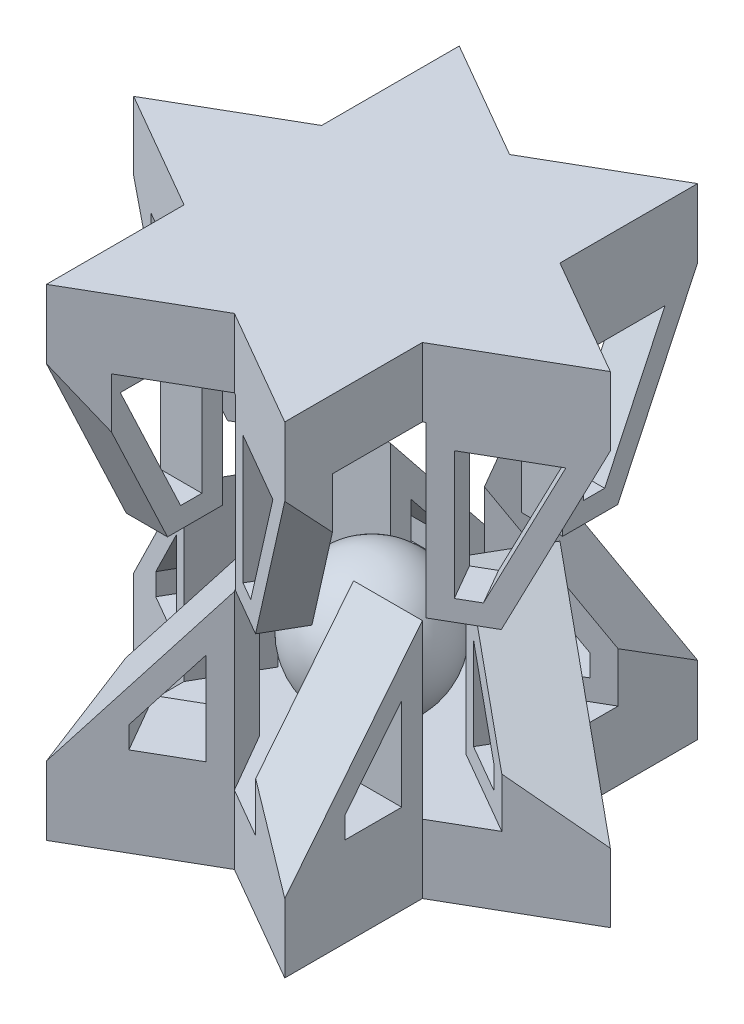
from build123d import *

# Parameters (mm, degrees)
BOSS_EXTRUDE1_DEPTH = 5
BOSS_EXTRUDE2_START = 30
BOSS_EXTRUDE2_DEPTH = 5
BOSS_EXTRUDE3_DEPTH = 5
CIRPATTERN3_COUNT   = 6
SKETCH6_W           = 10
SKETCH6_H           = 17.5
CUT_EXTRUDE2_DEPTH  = 5
CIRPATTERN4_COUNT   = 6
CUT_EXTRUDE3_DEPTH  = 5
CIRPATTERN5_COUNT   = 6
BOSS_EXTRUDE4_DEPTH = 3
CIRPATTERN6_COUNT   = 6
SKETCH9_W           = 6.930095711
SKETCH9_H           = 11.997305441
CUT_EXTRUDE4_DEPTH  = 3
CIRPATTERN7_COUNT   = 6


with BuildPart() as part:
    # Sketch2 → Boss-Extrude1 (new body)
    with BuildSketch(Plane(origin=(0, 0, 0), x_dir=(1, 0, 0), z_dir=(0, 1, 0))):
        Polygon((8.660254038, -15), (0, -10), (0, 0), (8.660254038, -5), align=None)
        Polygon((-8.660254038, -15), (-8.660254038, -5), (0, 0), (0, -10), align=None)
        Polygon((-17.320508076, 0), (-8.660254038, 5), (0, 0), (-8.660254038, -5), align=None)
        Polygon((0, 10), (0, 0), (-8.660254038, 5), (-8.660254038, 15), align=None)
        Polygon((8.660254038, 15), (8.660254038, 5), (0, 0), (0, 10), align=None)
        Polygon((17.320508076, 0), (8.660254038, -5), (0, 0), (8.660254038, 5), align=None)
    extrude(amount=BOSS_EXTRUDE1_DEPTH)

    # Sketch3 → Boss-Extrude3 (add)
    with BuildSketch(Plane.ZY.offset(8.660254038)):
        Polygon((-15, 5), (-5, 17.5), (-5, 5), align=None)
    boss_extrude3 = extrude(amount=-BOSS_EXTRUDE3_DEPTH)

    # CirPattern3: Boss-Extrude3 ×6 about axis
    cirpattern3_axis = Axis((0, 0, 0), (0, 1, 0))
    for i in range(1, CIRPATTERN3_COUNT):
        add(boss_extrude3.rotate(cirpattern3_axis, i * 360 / CIRPATTERN3_COUNT))

    # Sketch6 → Cut-Extrude2 (cut)
    with BuildSketch(Plane(origin=(4.330127019, 0, -7.5), x_dir=(-0.866025404, 0, -0.5), z_dir=(0.5, 0, -0.866025404))):
        with Locations((10, 8.75)):
            Rectangle(SKETCH6_W, SKETCH6_H)
    cut_extrude2 = extrude(amount=CUT_EXTRUDE2_DEPTH, mode=Mode.SUBTRACT)

    # CirPattern4: Cut-Extrude2 ×6 about axis
    cirpattern4_axis = Axis((0, 0, 0), (0, 1, 0))
    for i in range(1, CIRPATTERN4_COUNT):
        add(cut_extrude2.rotate(cirpattern4_axis, i * 360 / CIRPATTERN4_COUNT), mode=Mode.SUBTRACT)

    # Sketch7 → Cut-Extrude3 (cut)
    with BuildSketch(Plane(origin=(-1.830127019, 0, -3.169872981), x_dir=(0.866025404, 0, -0.5), z_dir=(0.5, 0, 0.866025404))):
        Polygon((10.613248654, 6.5), (10.613248654, 8.082267593), (6.5, 13.223828411), (6.5, 6.5), align=None)
    cut_extrude3 = extrude(amount=-CUT_EXTRUDE3_DEPTH, mode=Mode.SUBTRACT)

    # CirPattern5: Cut-Extrude3 ×6 about axis
    cirpattern5_axis = Axis((0, 0, 0), (0, 1, 0))
    for i in range(1, CIRPATTERN5_COUNT):
        add(cut_extrude3.rotate(cirpattern5_axis, i * 360 / CIRPATTERN5_COUNT), mode=Mode.SUBTRACT)


with BuildPart() as body_2:
    # Sketch2_3 → Boss-Extrude2 (new body)
    with BuildSketch(Plane(origin=(0, 0, 0), x_dir=(1, 0, 0), z_dir=(0, 1, 0)).offset(BOSS_EXTRUDE2_START)):
        Polygon((-8.660254038, 5), (-8.660254038, 15), (0, 10), (8.660254038, 15), (8.660254038, 5), (17.320508076, 0), (8.660254038, -5), (8.660254038, -15), (0, -10), (-8.660254038, -15), (-8.660254038, -5), (-17.320508076, 0), align=None)
    extrude(amount=BOSS_EXTRUDE2_DEPTH)

    # Sketch8 → Boss-Extrude4 (add)
    with BuildSketch(Plane(origin=(4.330127019, 0, -7.5), x_dir=(-0.866025404, 0, -0.5), z_dir=(0.5, 0, -0.866025404))):
        Polygon((15, 30), (5.2, 30), (5.2, 17.7), (9.2, 17.7), align=None)
        Polygon((8.248914998, 19.2), (12.634280852, 28.5), (6.7, 28.5), (6.7, 19.2), align=None, mode=Mode.SUBTRACT)
    boss_extrude4 = extrude(amount=-BOSS_EXTRUDE4_DEPTH)

    # CirPattern6: Boss-Extrude4 ×6 about axis
    cirpattern6_axis = Axis((0, 0, 0), (0, 1, 0))
    for i in range(1, CIRPATTERN6_COUNT):
        add(boss_extrude4.rotate(cirpattern6_axis, i * 360 / CIRPATTERN6_COUNT))

    # Sketch9 → Cut-Extrude4 (cut)
    with BuildSketch(Plane.ZY.offset(8.660254038)):
        with Locations((-11.534952145, 29.00134728)):
            Rectangle(SKETCH9_W, SKETCH9_H)
    cut_extrude4 = extrude(amount=CUT_EXTRUDE4_DEPTH, mode=Mode.SUBTRACT)

    # CirPattern7: Cut-Extrude4 ×6 about axis
    cirpattern7_axis = Axis((0, 0, 0), (0, 1, 0))
    for i in range(1, CIRPATTERN7_COUNT):
        add(cut_extrude4.rotate(cirpattern7_axis, i * 360 / CIRPATTERN7_COUNT), mode=Mode.SUBTRACT)


with BuildPart() as body_3:
    # Sketch4 → Revolve11 (revolve)
    with BuildSketch(Plane(origin=(0, 0, 0), x_dir=(0, 0, -1), z_dir=(1, 0, 0))):
        with BuildLine():
            Line((0, 15), (0, 5))
            ThreePointArc((0, 5), (5, 10), (0, 15))
        make_face()
    revolve(axis=Axis((0, 0, 0), (0, 1, 0)))


solid = Compound([part.part, body_2.part, body_3.part])
